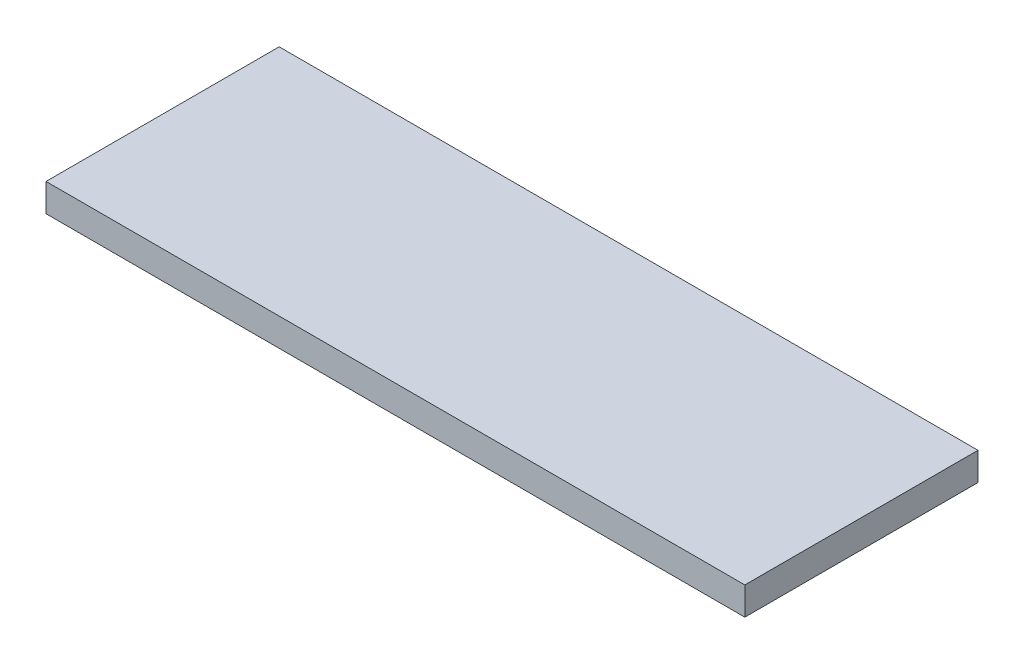
from build123d import *

# Parameters (mm, degrees)
SKETCH1_W           = 150
SKETCH1_H           = 50.05
BOSS_EXTRUDE2_DEPTH = 6


with BuildPart() as part:
    # Sketch1 → Boss-Extrude2 (new body)
    with BuildSketch(Plane(origin=(0, 0, 0), x_dir=(1, 0, 0), z_dir=(0, 1, 0))):
        with Locations((-75, 25.025)):
            Rectangle(SKETCH1_W, SKETCH1_H)
    extrude(amount=BOSS_EXTRUDE2_DEPTH)


solid = part.part
